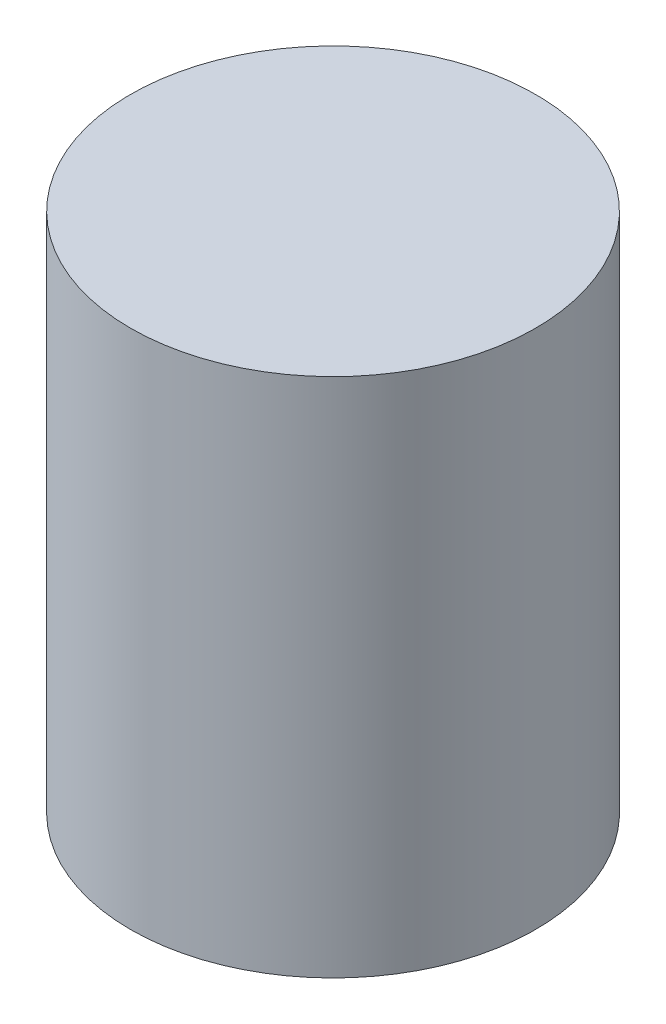
from build123d import *

# Parameters (mm, degrees)
SKETCH1_R           = 17.5
BOSS_EXTRUDE1_DEPTH = 45


with BuildPart() as part:
    # Sketch1 → Boss-Extrude1 (new body)
    with BuildSketch(Plane(origin=(0, 0, 0), x_dir=(1, 0, 0), z_dir=(0, 1, 0))):
        Circle(SKETCH1_R)
    extrude(amount=BOSS_EXTRUDE1_DEPTH)


solid = part.part
